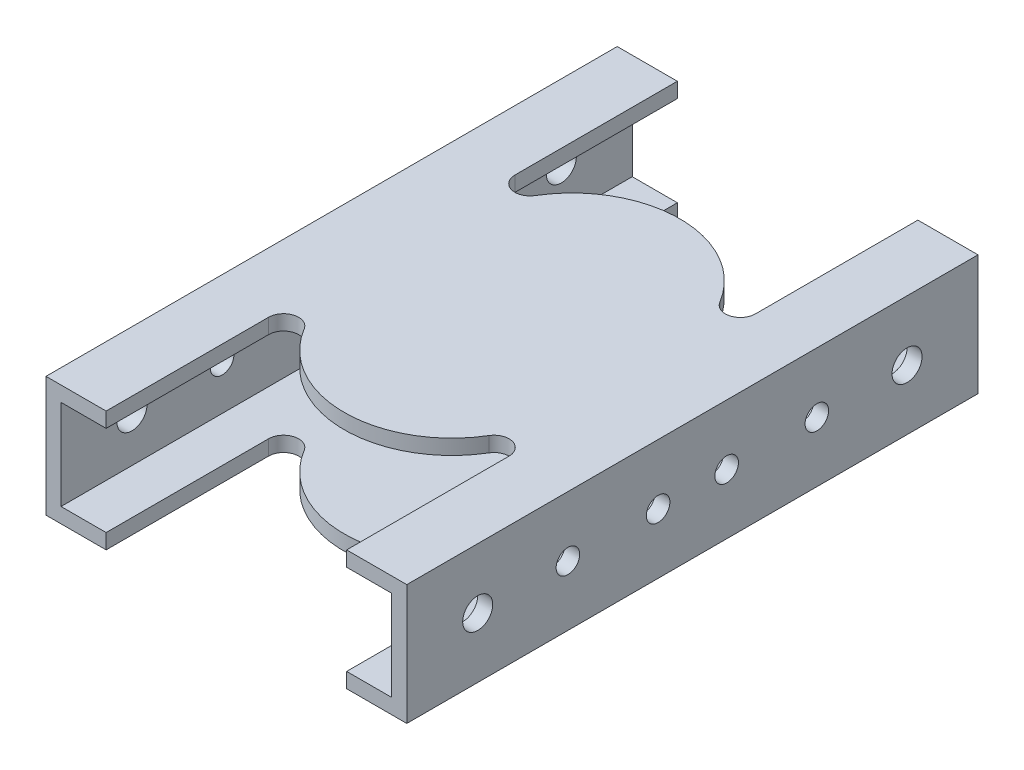
from build123d import *

# Parameters (mm, degrees)
SKETCH1_W           = 76.2
SKETCH1_H           = 25.4
SKETCH1_W_2         = 69.85
SKETCH1_H_2         = 19.05
EXTRUDE_THIN1_DEPTH = 146.05
CUT_EXTRUDE7_DEPTH  = 26.4
SKETCH7_R           = 3.175
CUT_EXTRUDE8_DEPTH  = 77.2
SKETCH8_R           = 2.4892
CUT_EXTRUDE9_DEPTH  = 77.2


with BuildPart() as part:
    # Sketch1 → Extrude-Thin1 (new body)
    with BuildSketch(Plane.XY):
        Rectangle(SKETCH1_W, SKETCH1_H)
        Rectangle(SKETCH1_W_2, SKETCH1_H_2, mode=Mode.SUBTRACT)
    extrude(amount=EXTRUDE_THIN1_DEPTH)

    # Sketch6 → Cut-Extrude7 (cut, through all)
    with BuildSketch(Plane(origin=(0, 12.7, 0), x_dir=(1, 0, 0), z_dir=(0, 1, 0))):
        with BuildLine():
            Line((-38.1, 0), (-38.1, -12.7))
            Line((-38.1, -12.7), (-25.4, -12.7))
            Line((-25.4, -12.7), (-25.4, -47.004160739))
            ThreePointArc((-25.4, -47.004160739), (-23.071797148, -50.064154136), (-19.501694746, -48.636408727))
            ThreePointArc((-19.501694746, -48.636408727), (0, -37.588701622), (19.501694746, -48.636408727))
            ThreePointArc((19.501694746, -48.636408727), (23.071797148, -50.064154136), (25.4, -47.004160739))
            Line((25.4, -47.004160739), (25.4, -12.7))
            Line((25.4, -12.7), (38.1, -12.7))
            Line((38.1, -12.7), (38.1, 0))
            Line((38.1, 0), (-38.1, 0))
        make_face()
    cut_extrude7 = extrude(amount=-CUT_EXTRUDE7_DEPTH, mode=Mode.SUBTRACT)

    # Sketch7 → Cut-Extrude8 (cut, through all)
    with BuildSketch(Plane(origin=(38.1, 0, 0), x_dir=(0, 0, -1), z_dir=(1, 0, 0))):
        with Locations((-27.686, 0)):
            Circle(SKETCH7_R)
    cut_extrude8 = extrude(amount=-CUT_EXTRUDE8_DEPTH, mode=Mode.SUBTRACT)

    # Mirror3: Cut-Extrude7, Cut-Extrude8 across plane
    add(cut_extrude7.mirror(Plane.XY.offset(73.025)), mode=Mode.SUBTRACT)
    add(cut_extrude8.mirror(Plane.XY.offset(73.025)), mode=Mode.SUBTRACT)

    # Sketch8 → Cut-Extrude9 (cut, through all)
    with BuildSketch(Plane.ZY.offset(38.1)):
        with Locations((46.736, 0)):
            Circle(SKETCH8_R)
        with Locations((99.314, 0)):
            Circle(SKETCH8_R)
        with Locations((80.264, 0)):
            Circle(SKETCH8_R)
        with Locations((65.786, 0)):
            Circle(SKETCH8_R)
    extrude(amount=-CUT_EXTRUDE9_DEPTH, mode=Mode.SUBTRACT)


solid = part.part
